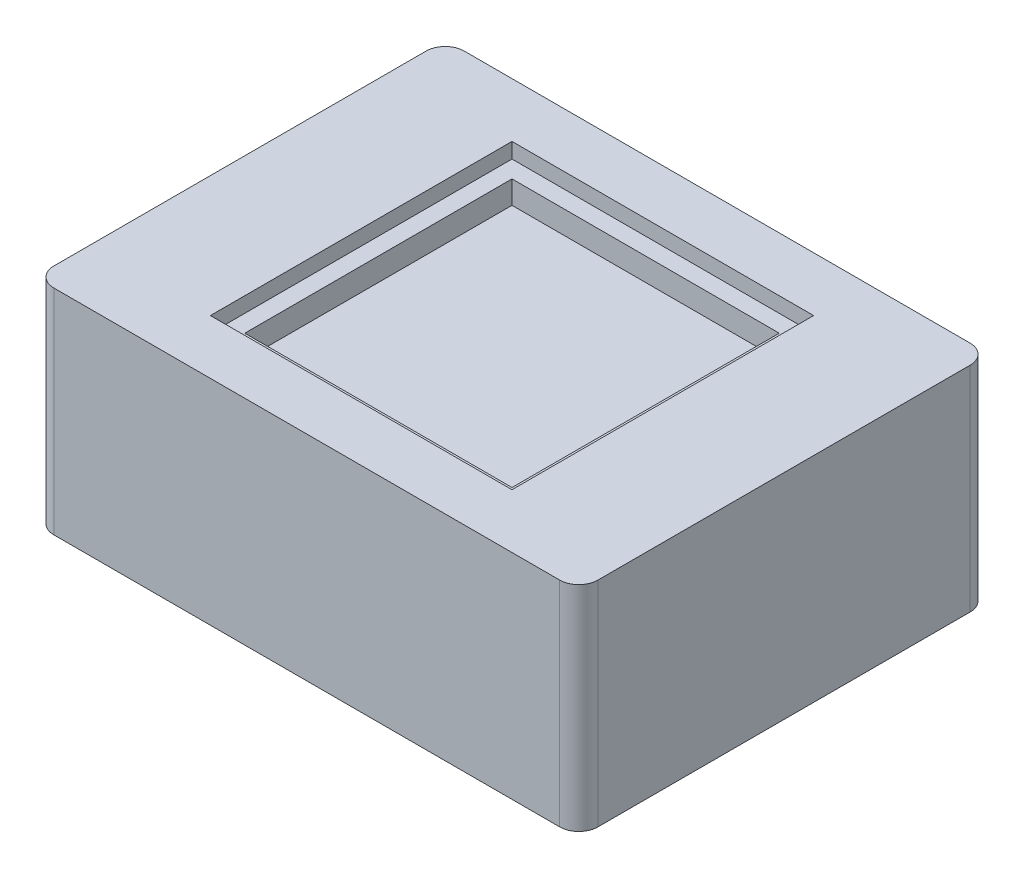
from build123d import *

# Parameters (mm, degrees)
SKETCH_1_W          = 28.5
SKETCH_1_H          = 21.5
EXTRUDE_1_DEPTH     = 11.2
FILLET_1_R          = 1
SKETCH_3_W          = 14
SKETCH_3_H          = 14
CUT_EXTRUDE_2_DEPTH = 2
SKETCH_4_W          = 15.8
SKETCH_4_H          = 15.8
CUT_EXTRUDE_3_DEPTH = 0.8


with BuildPart() as part:
    # 草图1 → 凸台-拉伸1 (new body)
    with BuildSketch(Plane(origin=(0, 0, 0), x_dir=(1, 0, 0), z_dir=(0, 1, 0))):
        Rectangle(SKETCH_1_W, SKETCH_1_H)
    extrude(amount=EXTRUDE_1_DEPTH)

    # 圆角1
    fillet_1_edges = [part.edges().sort_by_distance(p)[0] for p in [
        (14.25, 5.6, 10.75),
        (-14.25, 5.6, 10.75),
        (-14.25, 5.6, -10.75),
        (14.25, 5.6, -10.75),
    ]]
    fillet(fillet_1_edges, radius=FILLET_1_R)

    # 草图3 → 切除-拉伸2 (cut)
    with BuildSketch(Plane(origin=(0, 11.2, 0), x_dir=(1, 0, 0), z_dir=(0, 1, 0))):
        Rectangle(SKETCH_3_W, SKETCH_3_H)
    extrude(amount=-CUT_EXTRUDE_2_DEPTH, mode=Mode.SUBTRACT)

    # 草图4 → 切除-拉伸3 (cut)
    with BuildSketch(Plane(origin=(0, 11.2, 0), x_dir=(1, 0, 0), z_dir=(0, 1, 0))):
        Rectangle(SKETCH_4_W, SKETCH_4_H)
    extrude(amount=-CUT_EXTRUDE_3_DEPTH, mode=Mode.SUBTRACT)


solid = part.part
